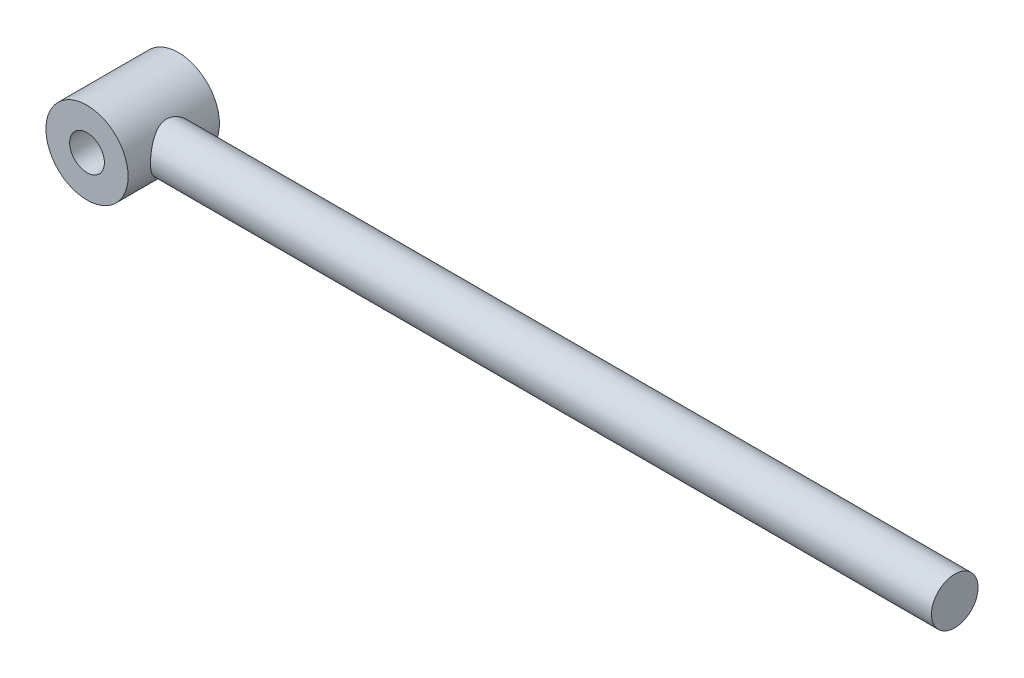
from build123d import *

# Parameters (mm, degrees)
SKETCH1_W               = 1800
SKETCH1_H               = 51
SKETCH2_R               = 90
SKETCH2_R_2             = 38
BOSS_EXTRUDE1_DEPTH     = 100
CUT_EXTRUDE1_DEPTH      = 1806.020775614
CUT_EXTRUDE1_DEPTH_BACK = 1806.020775614
SKETCH2_2_R             = 38


with BuildPart() as part:
    # Sketch1 → Revolve1 (revolve)
    with BuildSketch(Plane.XY):
        with Locations((900, 25.5)):
            Rectangle(SKETCH1_W, SKETCH1_H)
    revolve(axis=Axis((0, 0, 0), (1, 0, 0)))

    # Sketch2 → Boss-Extrude1 (add, symmetric)
    with BuildSketch(Plane.XY):
        Circle(SKETCH2_R)
        Circle(SKETCH2_R_2, mode=Mode.SUBTRACT)
    extrude(amount=BOSS_EXTRUDE1_DEPTH, both=True)

    # Sketch2_2 → Cut-Extrude1 (cut, two sides: drawn at the far end of the back side and taken through both)
    with BuildSketch(Plane.XY.offset(-CUT_EXTRUDE1_DEPTH_BACK)):
        Circle(SKETCH2_2_R)
    extrude(amount=CUT_EXTRUDE1_DEPTH + CUT_EXTRUDE1_DEPTH_BACK, mode=Mode.SUBTRACT)


solid = part.part
